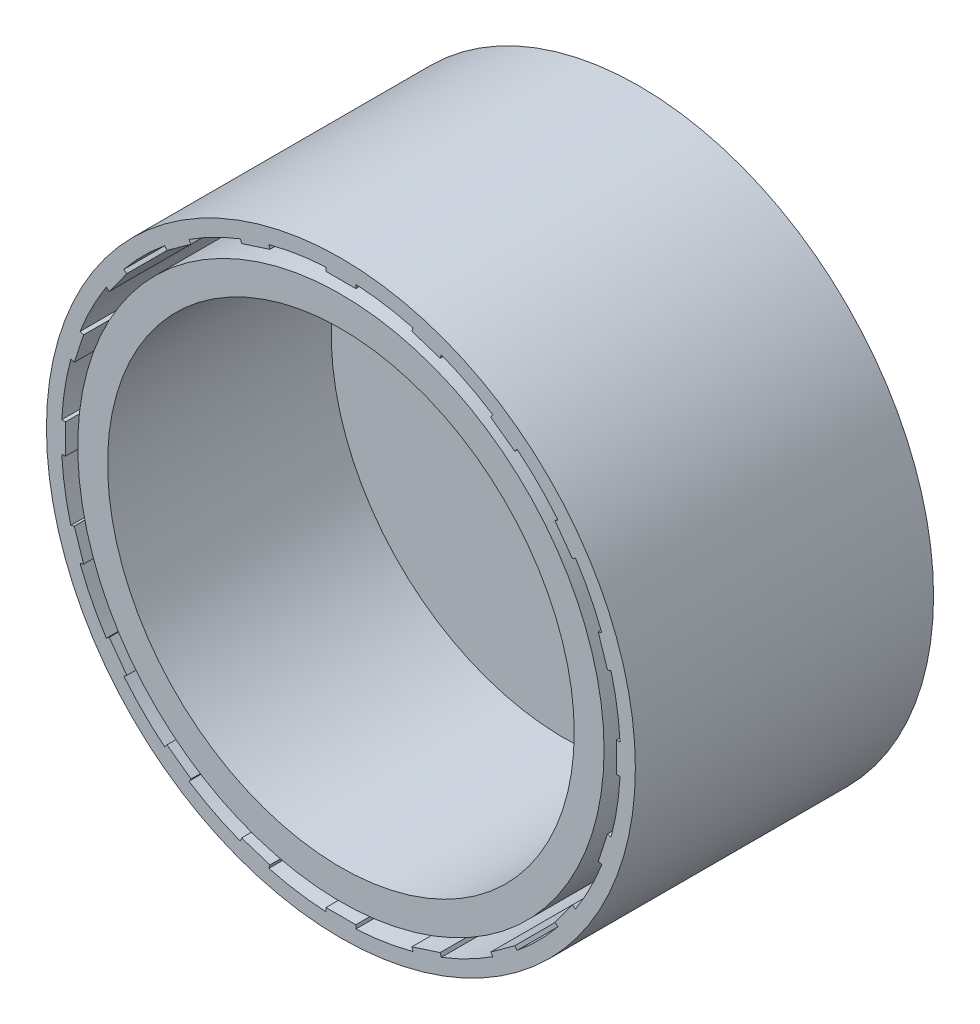
from build123d import *

# Parameters (mm, degrees)
SKETCH1_R           = 4.625
SKETCH1_R_2         = 1.625
BOSS_EXTRUDE1_DEPTH = 10
SKETCH1_3_R         = 19.75
SKETCH1_3_R_2       = 18.75
SKETCH1_3_R_3       = 17.65
SKETCH1_3_R_4       = 4.625
SKETCH1_3_R_5       = 15.65
SKETCH1_3_R_6       = 1.625
BOSS_EXTRUDE2_DEPTH = 5
SKETCH1_4_R         = 19.75
SKETCH1_4_R_2       = 18.75
SKETCH1_4_R_3       = 17.65
SKETCH1_4_R_4       = 15.65
BOSS_EXTRUDE3_DEPTH = 20
BOSS_EXTRUDE4_DEPTH = 20
SKETCH3_R           = 2
CUT_EXTRUDE1_DEPTH  = 35.352947472


with BuildPart() as part:
    # Sketch1 → Boss-Extrude1 (new body)
    with BuildSketch(Plane.XY):
        Circle(SKETCH1_R)
        Circle(SKETCH1_R_2, mode=Mode.SUBTRACT)
    extrude(amount=-BOSS_EXTRUDE1_DEPTH)



with BuildPart() as body_2:
    # Sketch1_3 → Boss-Extrude2 (new body)
    with BuildSketch(Plane.XY):
        Circle(SKETCH1_3_R)
        Circle(SKETCH1_3_R_2, mode=Mode.SUBTRACT)
        Circle(SKETCH1_3_R_2)
        Circle(SKETCH1_3_R_3, mode=Mode.SUBTRACT)
        Circle(SKETCH1_3_R_3)
        Circle(SKETCH1_3_R_4, mode=Mode.SUBTRACT)
        Circle(SKETCH1_3_R_5)
        Circle(SKETCH1_3_R_4, mode=Mode.SUBTRACT)
        Circle(SKETCH1_3_R_4)
        Circle(SKETCH1_3_R_6, mode=Mode.SUBTRACT)
    extrude(amount=BOSS_EXTRUDE2_DEPTH)


with BuildPart() as part_1:
    add(part.part)

    add(body_2.part)  # Boss-Extrude3 merges body 2
    # Sketch1_4 → Boss-Extrude3 (add)
    with BuildSketch(Plane.XY):
        Circle(SKETCH1_4_R)
        Circle(SKETCH1_4_R_2, mode=Mode.SUBTRACT)
        Circle(SKETCH1_4_R_3)
        Circle(SKETCH1_4_R_4, mode=Mode.SUBTRACT)
    extrude(amount=BOSS_EXTRUDE3_DEPTH)

    # Sketch2 → Boss-Extrude4 (add)
    with BuildSketch(Plane.XY):
        with BuildLine():
            Line((-4.757511558, 17.878182978), (-4.834765807, 18.115947107))
            ThreePointArc((-4.834765807, 18.115947107), (-5.794068645, 17.832309681), (-6.736878839, 17.497913119))
            Line((-6.736878839, 17.497913119), (-6.659624591, 17.260148989))
            Line((-6.659624591, 17.260148989), (-4.757511558, 17.878182978))
        make_face()
        with BuildLine():
            Line((-10.049324738, 15.533010498), (-10.196271051, 15.735264747))
            ThreePointArc((-10.196271051, 15.735264747), (-11.02097348, 15.169068645), (-11.814305039, 14.559694243))
            Line((-11.814305039, 14.559694243), (-11.667358726, 14.357439994))
            Line((-11.667358726, 14.357439994), (-10.049324738, 15.533010498))
        make_face()
        with BuildLine():
            Line((1, 18.473314343), (1, 18.723314343))
            ThreePointArc((1, 18.723314343), (0, 18.75), (-1, 18.723314343))
            Line((-1, 18.723314343), (-1, 18.473314343))
            Line((-1, 18.473314343), (1, 18.473314343))
        make_face()
        with BuildLine():
            Line((4.834765807, 18.115947107), (4.757511558, 17.878182978))
            Line((4.757511558, 17.878182978), (6.659624591, 17.260148989))
            Line((6.659624591, 17.260148989), (6.736878839, 17.497913119))
            ThreePointArc((6.736878839, 17.497913119), (5.794068645, 17.832309681), (4.834765807, 18.115947107))
        make_face()
        with BuildLine():
            ThreePointArc((11.814305039, 14.559694243), (11.02097348, 15.169068645), (10.196271051, 15.735264747))
            Line((10.196271051, 15.735264747), (10.049324738, 15.533010498))
            Line((10.049324738, 15.533010498), (11.667358726, 14.357439994))
            Line((11.667358726, 14.357439994), (11.814305039, 14.559694243))
        make_face()
        with BuildLine():
            ThreePointArc((15.735264747, 10.196271051), (15.169068645, 11.02097348), (14.559694243, 11.814305039))
            Line((14.559694243, 11.814305039), (14.357439994, 11.667358726))
            Line((14.357439994, 11.667358726), (15.533010498, 10.049324738))
            Line((15.533010498, 10.049324738), (15.735264747, 10.196271051))
        make_face()
        with BuildLine():
            ThreePointArc((18.115947107, 4.834765807), (17.832309681, 5.794068645), (17.497913119, 6.736878839))
            Line((17.497913119, 6.736878839), (17.260148989, 6.659624591))
            Line((17.260148989, 6.659624591), (17.878182978, 4.757511558))
            Line((17.878182978, 4.757511558), (18.115947107, 4.834765807))
        make_face()
        with BuildLine():
            ThreePointArc((18.75, 0), (18.743327399, 0.500177999), (18.723314343, 1))
            Line((18.723314343, 1), (18.473314343, 1))
            Line((18.473314343, 1), (18.473314343, -1))
            Line((18.473314343, -1), (18.723314343, -1))
            ThreePointArc((18.723314343, -1), (18.743327399, -0.500177999), (18.75, 0))
        make_face()
        with BuildLine():
            ThreePointArc((17.497913119, -6.736878839), (17.832309681, -5.794068645), (18.115947107, -4.834765807))
            Line((18.115947107, -4.834765807), (17.878182978, -4.757511558))
            Line((17.878182978, -4.757511558), (17.260148989, -6.659624591))
            Line((17.260148989, -6.659624591), (17.497913119, -6.736878839))
        make_face()
        with BuildLine():
            ThreePointArc((14.559694243, -11.814305039), (15.169068645, -11.02097348), (15.735264747, -10.196271051))
            Line((15.735264747, -10.196271051), (15.533010498, -10.049324738))
            Line((15.533010498, -10.049324738), (14.357439994, -11.667358726))
            Line((14.357439994, -11.667358726), (14.559694243, -11.814305039))
        make_face()
        with BuildLine():
            ThreePointArc((10.196271051, -15.735264747), (11.02097348, -15.169068645), (11.814305039, -14.559694243))
            Line((11.814305039, -14.559694243), (11.667358726, -14.357439994))
            Line((11.667358726, -14.357439994), (10.049324738, -15.533010498))
            Line((10.049324738, -15.533010498), (10.196271051, -15.735264747))
        make_face()
        with BuildLine():
            ThreePointArc((4.834765807, -18.115947107), (5.794068645, -17.832309681), (6.736878839, -17.497913119))
            Line((6.736878839, -17.497913119), (6.659624591, -17.260148989))
            Line((6.659624591, -17.260148989), (4.757511558, -17.878182978))
            Line((4.757511558, -17.878182978), (4.834765807, -18.115947107))
        make_face()
        with BuildLine():
            ThreePointArc((-1, -18.723314343), (0, -18.75), (1, -18.723314343))
            Line((1, -18.723314343), (1, -18.473314343))
            Line((1, -18.473314343), (-1, -18.473314343))
            Line((-1, -18.473314343), (-1, -18.723314343))
        make_face()
        with BuildLine():
            Line((-6.659624591, -17.260148989), (-6.736878839, -17.497913119))
            ThreePointArc((-6.736878839, -17.497913119), (-5.794068645, -17.832309681), (-4.834765807, -18.115947107))
            Line((-4.834765807, -18.115947107), (-4.757511558, -17.878182978))
            Line((-4.757511558, -17.878182978), (-6.659624591, -17.260148989))
        make_face()
        with BuildLine():
            Line((-11.667358726, -14.357439994), (-11.814305039, -14.559694243))
            ThreePointArc((-11.814305039, -14.559694243), (-11.02097348, -15.169068645), (-10.196271051, -15.735264747))
            Line((-10.196271051, -15.735264747), (-10.049324738, -15.533010498))
            Line((-10.049324738, -15.533010498), (-11.667358726, -14.357439994))
        make_face()
        with BuildLine():
            Line((-15.533010498, -10.049324738), (-15.735264747, -10.196271051))
            ThreePointArc((-15.735264747, -10.196271051), (-15.169068645, -11.02097348), (-14.559694243, -11.814305039))
            Line((-14.559694243, -11.814305039), (-14.357439994, -11.667358726))
            Line((-14.357439994, -11.667358726), (-15.533010498, -10.049324738))
        make_face()
        with BuildLine():
            Line((-17.878182978, -4.757511558), (-18.115947107, -4.834765807))
            ThreePointArc((-18.115947107, -4.834765807), (-17.832309681, -5.794068645), (-17.497913119, -6.736878839))
            Line((-17.497913119, -6.736878839), (-17.260148989, -6.659624591))
            Line((-17.260148989, -6.659624591), (-17.878182978, -4.757511558))
        make_face()
        with BuildLine():
            Line((-18.473314343, 1), (-18.723314343, 1))
            ThreePointArc((-18.723314343, 1), (-18.75, 0), (-18.723314343, -1))
            Line((-18.723314343, -1), (-18.473314343, -1))
            Line((-18.473314343, -1), (-18.473314343, 1))
        make_face()
        with BuildLine():
            Line((-14.357439994, 11.667358726), (-14.559694243, 11.814305039))
            ThreePointArc((-14.559694243, 11.814305039), (-15.169068645, 11.02097348), (-15.735264747, 10.196271051))
            Line((-15.735264747, 10.196271051), (-15.533010498, 10.049324738))
            Line((-15.533010498, 10.049324738), (-14.357439994, 11.667358726))
        make_face()
        with BuildLine():
            Line((-17.260148989, 6.659624591), (-17.497913119, 6.736878839))
            ThreePointArc((-17.497913119, 6.736878839), (-17.832309681, 5.794068645), (-18.115947107, 4.834765807))
            Line((-18.115947107, 4.834765807), (-17.878182978, 4.757511558))
            Line((-17.878182978, 4.757511558), (-17.260148989, 6.659624591))
        make_face()
    extrude(amount=BOSS_EXTRUDE4_DEPTH)

    # Sketch3 → Cut-Extrude1 (cut, through all)
    with BuildSketch(Plane(origin=(0, 0, 0), x_dir=(1, 0, 0), z_dir=(0, 1, 0))):
        with Locations(Location((0, 5, 0), (0, 0, 270))):
            Circle(SKETCH3_R)
    extrude(amount=-CUT_EXTRUDE1_DEPTH, mode=Mode.SUBTRACT)


solid = part_1.part
